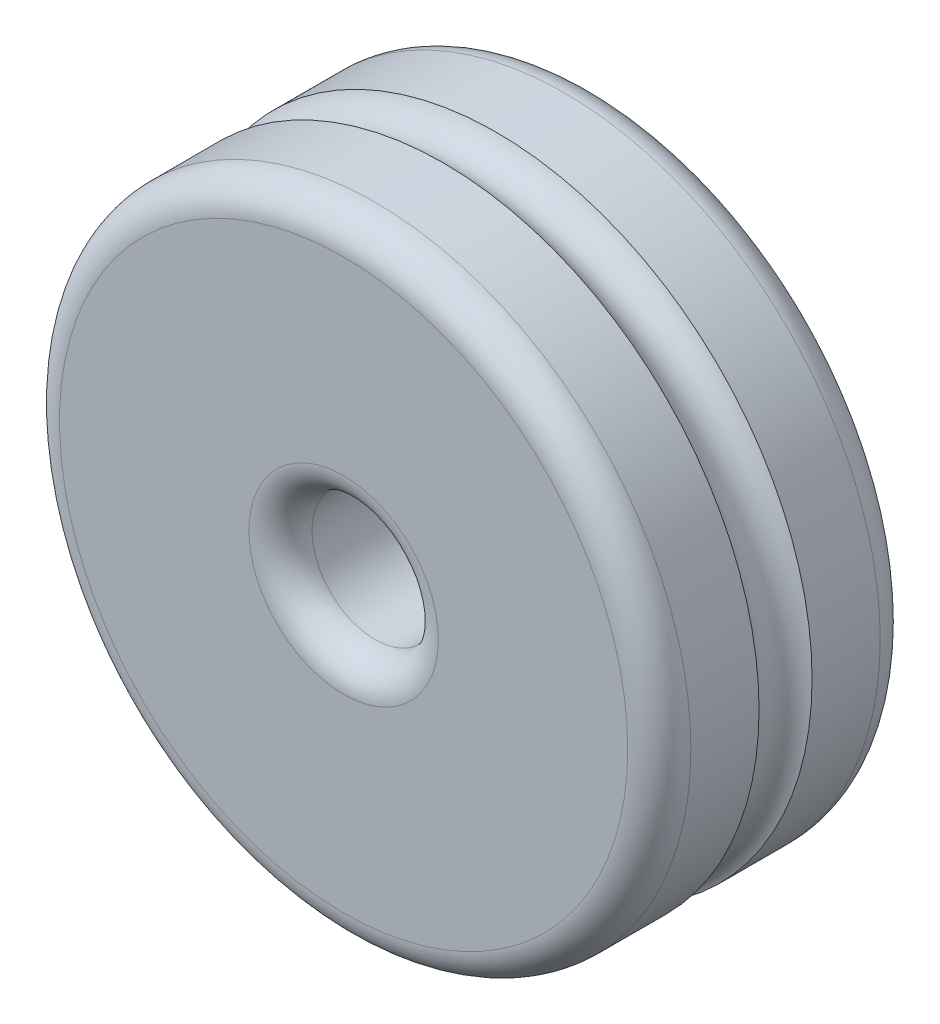
from build123d import *

# Parameters (mm, degrees)
BOSS_EXTRUDE1_DEPTH      = 20
BOSS_EXTRUDE1_DEPTH_BACK = 20
SKETCH1_R                = 50
SKETCH1_R_2              = 10
FILLET1_R                = 5
SKETCH3_R                = 4.520910571


with BuildPart() as part:
    # Sketch1 → Boss-Extrude1 (new, two sides: drawn at the far end of the back side and taken through both)
    with BuildSketch(Plane.XY.offset(-BOSS_EXTRUDE1_DEPTH_BACK)):
        Circle(SKETCH1_R)
        Circle(SKETCH1_R_2, mode=Mode.SUBTRACT)
    extrude(amount=BOSS_EXTRUDE1_DEPTH + BOSS_EXTRUDE1_DEPTH_BACK)

    # Fillet1
    fillet1_edges = [part.edges().sort_by_distance(p)[0] for p in [
        (-10, 0, -20),
        (-10, 0, 20),
        (-50, 0, 20),
        (-50, 0, -20),
    ]]
    fillet(fillet1_edges, radius=FILLET1_R)

    # Sketch3 → Cut-Revolve1 (revolve, cut)
    with BuildSketch(Plane(origin=(0, 0, 0), x_dir=(1, 0, 0), z_dir=(0, 1, 0))):
        with Locations((-51.671542469, 0)):
            Circle(SKETCH3_R)
    revolve(axis=Axis((0, 0, -9.930437496), (0, 0, 1)), mode=Mode.SUBTRACT)


solid = part.part
